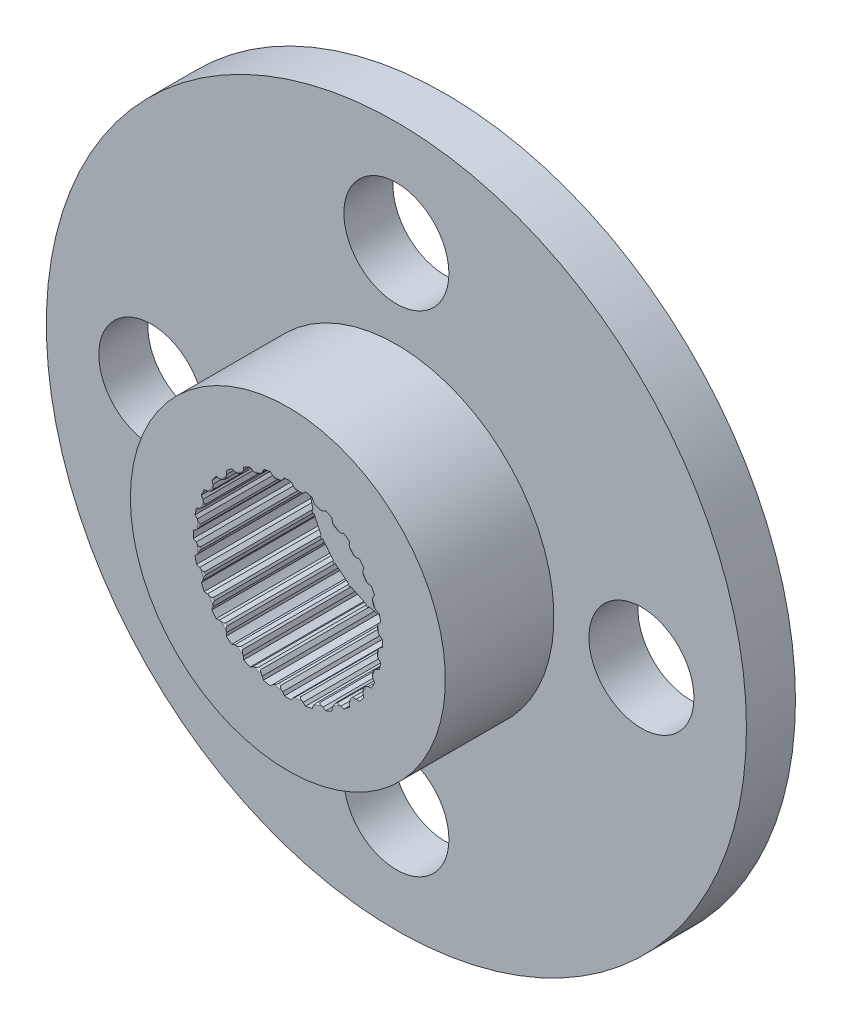
from build123d import *

# Parameters (mm, degrees)
CROQUIS1_R              = 10
CROQUIS1_R_2            = 1.5
SALIENTE_EXTRUIR1_DEPTH = 1.4
CROQUIS3_R              = 4.5
CROQUIS3_R_2            = 2.55
SALIENTE_EXTRUIR3_DEPTH = 3.1
CORTAR_EXTRUIR2_DEPTH   = 3.4
REDONDEO1_R             = 0.05
MATRIZC1_COUNT          = 28


with BuildPart() as part:
    # Croquis1 → Saliente-Extruir1 (new body)
    with BuildSketch(Plane.XY):
        Circle(CROQUIS1_R)
        with Locations((-7, 0)):
            Circle(CROQUIS1_R_2, mode=Mode.SUBTRACT)
        with Locations((0, 7)):
            Circle(CROQUIS1_R_2, mode=Mode.SUBTRACT)
        with Locations((0, -7)):
            Circle(CROQUIS1_R_2, mode=Mode.SUBTRACT)
        with Locations((7, 0)):
            Circle(CROQUIS1_R_2, mode=Mode.SUBTRACT)
        Circle(CROQUIS1_R_2, mode=Mode.SUBTRACT)
    extrude(amount=SALIENTE_EXTRUIR1_DEPTH)

    # Croquis3 → Saliente-Extruir3 (add)
    with BuildSketch(Plane.XY.offset(1.4)):
        with Locations(Location((0, 0, 0), (0, 0, 180))):
            Circle(CROQUIS3_R)
        with Locations(Location((0, 0, 0), (0, 0, 180))):
            Circle(CROQUIS3_R_2, mode=Mode.SUBTRACT)
    extrude(amount=SALIENTE_EXTRUIR3_DEPTH)

    # Croquis4 → Cortar-Extruir2 (cut)
    with BuildSketch(Plane.XY.offset(4.5)):
        with BuildLine():
            Line((0, 2.7), (0, 2.55))
            ThreePointArc((0, 2.55), (0.125150818, 2.546927025), (0.25, 2.537715508))
            Line((0.25, 2.537715508), (0.15, 2.62))
            Line((0.15, 2.62), (0.1, 2.698147513))
            ThreePointArc((0.1, 2.698147513), (0.050008579, 2.699536838), (0, 2.7))
        make_face()
        with BuildLine():
            ThreePointArc((-0.25, 2.537715508), (-0.125150818, 2.546927025), (0, 2.55))
            Line((0, 2.55), (0, 2.7))
            ThreePointArc((0, 2.7), (-0.050008579, 2.699536838), (-0.1, 2.698147513))
            Line((-0.1, 2.698147513), (-0.15, 2.62))
            Line((-0.15, 2.62), (-0.25, 2.537715508))
        make_face()
        with BuildLine():
            Line((0, 2.55), (0, 2.497452058))
            Line((0, 2.497452058), (0.246033494, 2.497452058))
            Line((0.246033494, 2.497452058), (0.25, 2.537715508))
            ThreePointArc((0.25, 2.537715508), (0.125150818, 2.546927025), (0, 2.55))
        make_face()
        with BuildLine():
            Line((-0.246033494, 2.497452058), (0, 2.497452058))
            Line((0, 2.497452058), (0, 2.55))
            ThreePointArc((0, 2.55), (-0.125150818, 2.546927025), (-0.25, 2.537715508))
            Line((-0.25, 2.537715508), (-0.246033494, 2.497452058))
        make_face()
    cortar_extruir2 = extrude(amount=-CORTAR_EXTRUIR2_DEPTH, mode=Mode.SUBTRACT)

    # Redondeo1
    redondeo1_edges = [part.edges().sort_by_distance(p)[0] for p in [
        (0, -2.55, 4.5),
    ]]
    fillet(redondeo1_edges, radius=REDONDEO1_R)

    # MatrizC1: Cortar-Extruir2 ×28 about axis
    matrizc1_axis = Axis((0, 0, 0), (0, 0, 1))
    for i in range(1, MATRIZC1_COUNT):
        add(cortar_extruir2.rotate(matrizc1_axis, i * 360 / MATRIZC1_COUNT), mode=Mode.SUBTRACT)


solid = part.part
